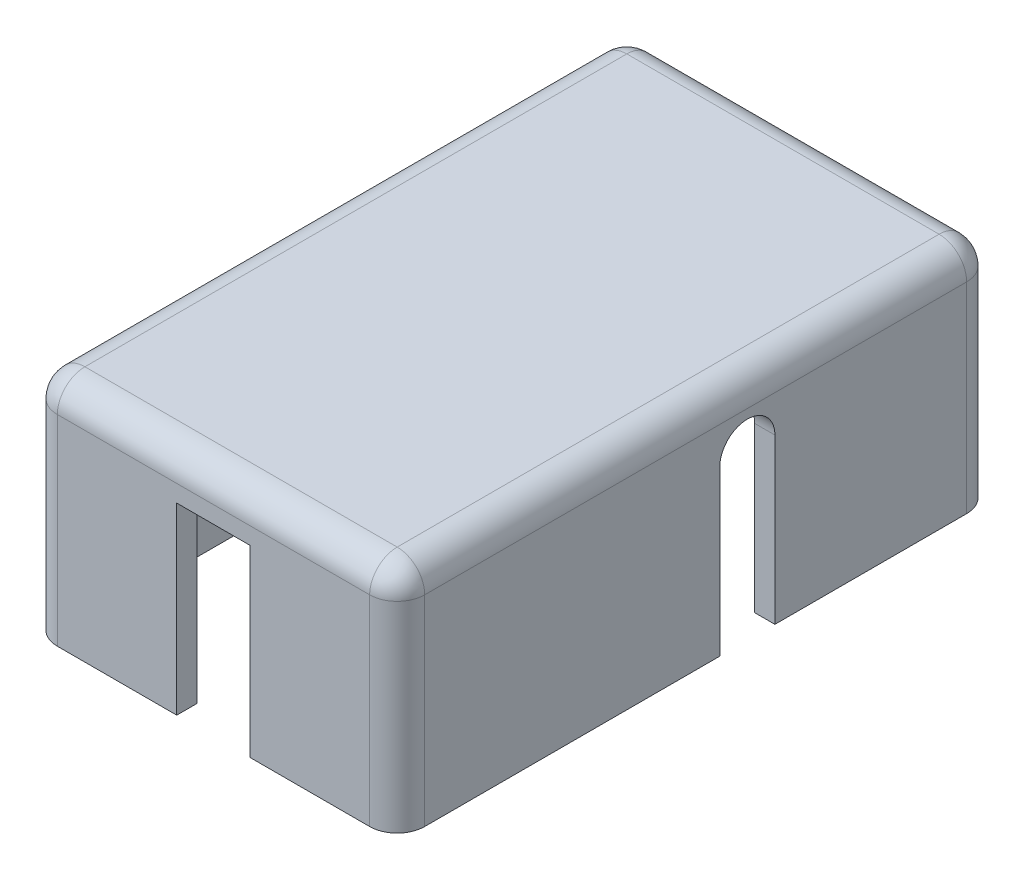
from build123d import *

# Parameters (mm, degrees)
SKETCH2_W           = 40
SKETCH2_H           = 65
SKETCH2_W_2         = 35.6
SKETCH2_H_2         = 60.6
BOSS_EXTRUDE1_DEPTH = 21.85
CUT_EXTRUDE1_DEPTH  = 37.8
SKETCH10_W          = 5
SKETCH10_H          = 15
SKETCH10_W_2        = 7
SKETCH10_H_2        = 20.35
CUT_EXTRUDE2_DEPTH  = 2.2
SKETCH11_W          = 8
SKETCH11_H          = 20
CUT_EXTRUDE3_DEPTH  = 2.2
SKETCH8_W           = 40
SKETCH8_H           = 65
BOSS_EXTRUDE2_DEPTH = 3
FILLET1_R           = 3


with BuildPart() as part:
    # Sketch2 → Boss-Extrude1 (new body)
    with BuildSketch(Plane(origin=(0, 0, 0), x_dir=(-1, 0, 0), z_dir=(0, -1, 0))):
        Rectangle(SKETCH2_W, SKETCH2_H)
        Rectangle(SKETCH2_W_2, SKETCH2_H_2, mode=Mode.SUBTRACT)
    extrude(amount=-BOSS_EXTRUDE1_DEPTH)

    # Sketch9 → Cut-Extrude1 (cut)
    with BuildSketch(Plane(origin=(20, 0, 0), x_dir=(0, 0, -1), z_dir=(1, 0, 0))):
        with BuildLine():
            Line((2.623584384, 17.85), (2.623584384, 0))
            Line((2.623584384, 0), (8.623584384, 0))
            Line((8.623584384, 0), (8.623584384, 17.85))
            ThreePointArc((8.623584384, 17.85), (5.623584384, 20.85), (2.623584384, 17.85))
        make_face()
    cut_extrude1 = extrude(amount=-CUT_EXTRUDE1_DEPTH, mode=Mode.SUBTRACT)

    # Mirror1: Cut-Extrude1 across plane
    add(cut_extrude1.mirror(Plane(origin=(0, 0, 0), x_dir=(0, 0, 1), z_dir=(1, 0, 0))), mode=Mode.SUBTRACT)

    # Sketch10 → Cut-Extrude2 (cut)
    with BuildSketch(Plane(origin=(0, 0, -32.5), x_dir=(-1, 0, 0), z_dir=(0, 0, -1))):
        with Locations((-10.385, 12.57)):
            Rectangle(SKETCH10_W, SKETCH10_H)
        with Locations((4.145, 10.175)):
            Rectangle(SKETCH10_W_2, SKETCH10_H_2)
    extrude(amount=-CUT_EXTRUDE2_DEPTH, mode=Mode.SUBTRACT)

    # Sketch11 → Cut-Extrude3 (cut)
    with BuildSketch(Plane.XY.offset(32.5)):
        with Locations((0, 10)):
            Rectangle(SKETCH11_W, SKETCH11_H)
    extrude(amount=-CUT_EXTRUDE3_DEPTH, mode=Mode.SUBTRACT)

    # Sketch8 → Boss-Extrude2 (add)
    with BuildSketch(Plane(origin=(0, 21.85, 0), x_dir=(1, 0, 0), z_dir=(0, 1, 0))):
        Rectangle(SKETCH8_W, SKETCH8_H)
    extrude(amount=BOSS_EXTRUDE2_DEPTH)

    # Fillet1
    fillet1_edges = [part.edges().sort_by_distance(p)[0] for p in [
        (-20, 12.425, 32.5),
        (20, 12.425, 32.5),
        (20, 12.425, -32.5),
        (-20, 12.425, -32.5),
        (-20, 24.85, 0),
        (0, 24.85, 32.5),
        (20, 24.85, 0),
        (0, 24.85, -32.5),
    ]]
    fillet(fillet1_edges, radius=FILLET1_R)


solid = part.part
